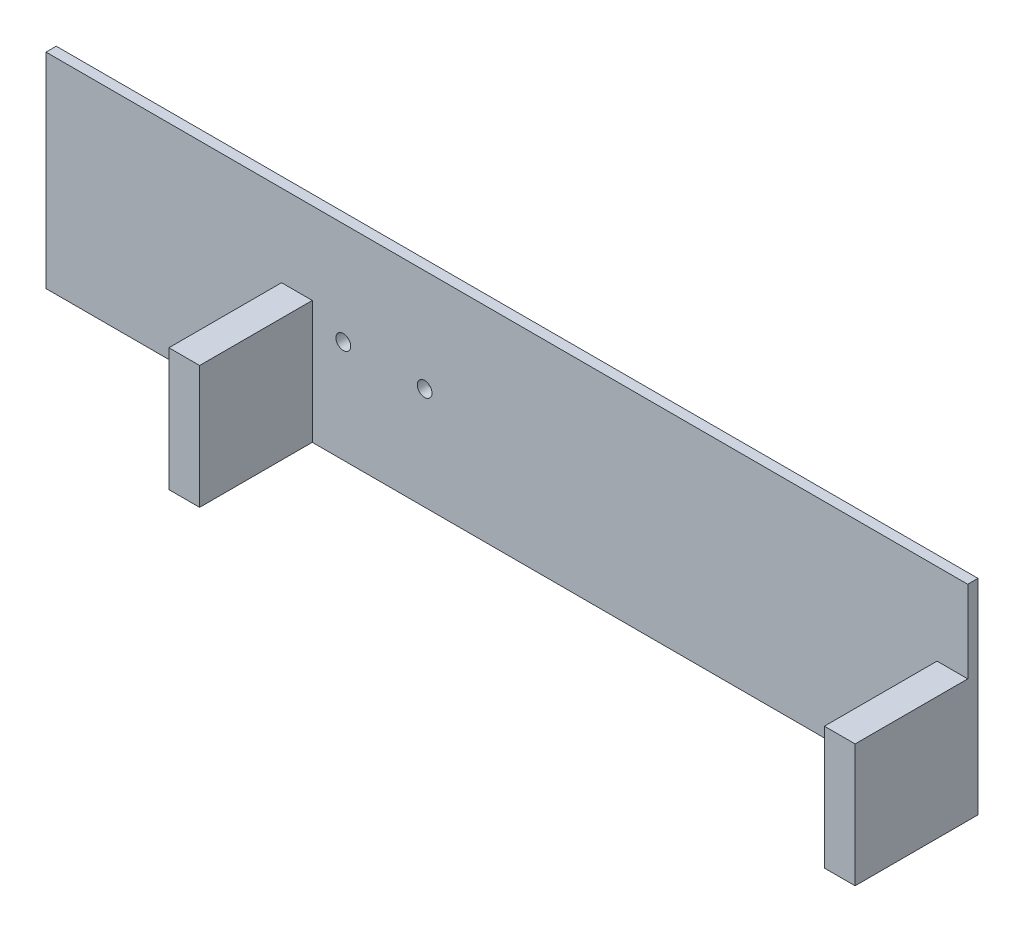
from build123d import *

# Parameters (mm, degrees)
SKETCH1_W               = 450
SKETCH1_H               = 100
BOSS_EXTRUDE1_DEPTH     = 5
SKETCH2_W               = 15
SKETCH2_H               = 60
BOSS_EXTRUDE2_DEPTH     = 55
SKETCH3_R               = 3.6
CUT_EXTRUDE1_DEPTH      = 56
CUT_EXTRUDE1_DEPTH_BACK = 6


with BuildPart() as part:
    # Sketch1 → Boss-Extrude1 (new body)
    with BuildSketch(Plane.XY):
        Rectangle(SKETCH1_W, SKETCH1_H)
    extrude(amount=BOSS_EXTRUDE1_DEPTH)

    # Sketch2 → Boss-Extrude2 (add)
    with BuildSketch(Plane.XY.offset(5)):
        with Locations((217.5, -20)):
            Rectangle(SKETCH2_W, SKETCH2_H)
        with Locations((-102.5, -20)):
            Rectangle(SKETCH2_W, SKETCH2_H)
    extrude(amount=BOSS_EXTRUDE2_DEPTH)

    # Sketch3 → Cut-Extrude1 (cut, two sides)
    with BuildSketch(Plane.XY.offset(5)) as cut_extrude1_sk:
        with Locations((-79.85, 0)):
            Circle(SKETCH3_R)
        with Locations((-40.15, 0)):
            Circle(SKETCH3_R)
    extrude(amount=CUT_EXTRUDE1_DEPTH, mode=Mode.SUBTRACT)
    extrude(cut_extrude1_sk.sketch, amount=-CUT_EXTRUDE1_DEPTH_BACK, mode=Mode.SUBTRACT)


solid = part.part
